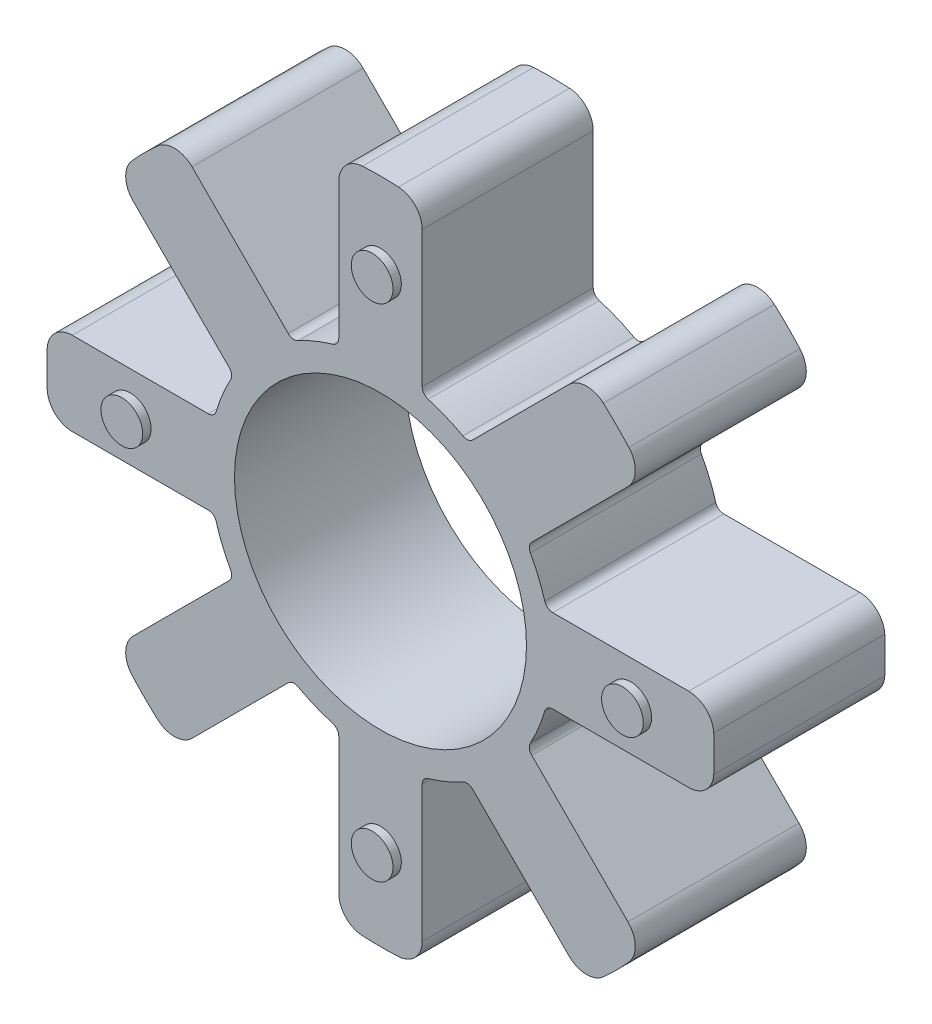
from build123d import *

# Parameters (mm, degrees)
SKETCH1_R           = 17.5
BOSS_EXTRUDE1_DEPTH = 10.25
SKETCH2_R           = 2.5
BOSS_EXTRUDE2_DEPTH = 1


with BuildPart() as part:
    # Sketch1 → Boss-Extrude1 (new body, symmetric)
    with BuildSketch(Plane.XY):
        with BuildLine():
            Line((-5, 36.945906404), (-5, 20.645822822))
            ThreePointArc((-5, 20.645822822), (-5.200290751, 20.04543535), (-5.720930233, 19.685551993))
            ThreePointArc((-5.720930233, 19.685551993), (-7.845010363, 18.939530416), (-9.874478744, 17.965095868))
            ThreePointArc((-9.874478744, 17.965095868), (-10.497102414, 17.851424122), (-11.063267415, 18.134335227))
            Line((-11.063267415, 18.134335227), (-22.589167049, 29.660234861))
            ThreePointArc((-22.589167049, 29.660234861), (-24.629376661, 30.537817825), (-26.714040425, 29.771799478))
            ThreePointArc((-26.714040425, 29.771799478), (-28.284271247, 28.284271247), (-29.771799478, 26.714040425))
            ThreePointArc((-29.771799478, 26.714040425), (-30.537817825, 24.629376661), (-29.660234861, 22.589167049))
            Line((-29.660234861, 22.589167049), (-18.134335227, 11.063267415))
            ThreePointArc((-18.134335227, 11.063267415), (-17.851424122, 10.497102414), (-17.965095868, 9.874478744))
            ThreePointArc((-17.965095868, 9.874478744), (-18.939530416, 7.845010363), (-19.685551993, 5.720930233))
            ThreePointArc((-19.685551993, 5.720930233), (-20.04543535, 5.200290751), (-20.645822822, 5))
            Line((-20.645822822, 5), (-36.945906404, 5))
            ThreePointArc((-36.945906404, 5), (-39.00909732, 4.177898814), (-39.941520437, 2.162162162))
            ThreePointArc((-39.941520437, 2.162162162), (-40, 0), (-39.941520437, -2.162162162))
            ThreePointArc((-39.941520437, -2.162162162), (-39.00909732, -4.177898814), (-36.945906404, -5))
            Line((-36.945906404, -5), (-20.645822822, -5))
            ThreePointArc((-20.645822822, -5), (-20.04543535, -5.200290751), (-19.685551993, -5.720930233))
            ThreePointArc((-19.685551993, -5.720930233), (-18.939530416, -7.845010363), (-17.965095868, -9.874478744))
            ThreePointArc((-17.965095868, -9.874478744), (-17.851424122, -10.497102414), (-18.134335227, -11.063267415))
            Line((-18.134335227, -11.063267415), (-29.660234861, -22.589167049))
            ThreePointArc((-29.660234861, -22.589167049), (-30.537817825, -24.629376661), (-29.771799478, -26.714040425))
            ThreePointArc((-29.771799478, -26.714040425), (-28.284271247, -28.284271247), (-26.714040425, -29.771799478))
            ThreePointArc((-26.714040425, -29.771799478), (-24.629376661, -30.537817825), (-22.589167049, -29.660234861))
            Line((-22.589167049, -29.660234861), (-11.063267415, -18.134335227))
            ThreePointArc((-11.063267415, -18.134335227), (-10.497102414, -17.851424122), (-9.874478744, -17.965095868))
            ThreePointArc((-9.874478744, -17.965095868), (-7.845010363, -18.939530416), (-5.720930233, -19.685551993))
            ThreePointArc((-5.720930233, -19.685551993), (-5.200290751, -20.04543535), (-5, -20.645822822))
            Line((-5, -20.645822822), (-5, -36.945906404))
            ThreePointArc((-5, -36.945906404), (-4.177898814, -39.00909732), (-2.162162162, -39.941520437))
            ThreePointArc((-2.162162162, -39.941520437), (0, -40), (2.162162162, -39.941520437))
            ThreePointArc((2.162162162, -39.941520437), (4.177898814, -39.00909732), (5, -36.945906404))
            Line((5, -36.945906404), (5, -20.645822822))
            ThreePointArc((5, -20.645822822), (5.200290751, -20.04543535), (5.720930233, -19.685551993))
            ThreePointArc((5.720930233, -19.685551993), (7.845010363, -18.939530416), (9.874478744, -17.965095868))
            ThreePointArc((9.874478744, -17.965095868), (10.497102414, -17.851424122), (11.063267415, -18.134335227))
            Line((11.063267415, -18.134335227), (22.589167049, -29.660234861))
            ThreePointArc((22.589167049, -29.660234861), (24.629376661, -30.537817825), (26.714040425, -29.771799478))
            ThreePointArc((26.714040425, -29.771799478), (28.284271247, -28.284271247), (29.771799478, -26.714040425))
            ThreePointArc((29.771799478, -26.714040425), (30.537817825, -24.629376661), (29.660234861, -22.589167049))
            Line((29.660234861, -22.589167049), (18.134335227, -11.063267415))
            ThreePointArc((18.134335227, -11.063267415), (17.851424122, -10.497102414), (17.965095868, -9.874478744))
            ThreePointArc((17.965095868, -9.874478744), (18.939530416, -7.845010363), (19.685551993, -5.720930233))
            ThreePointArc((19.685551993, -5.720930233), (20.04543535, -5.200290751), (20.645822822, -5))
            Line((20.645822822, -5), (36.945906404, -5))
            ThreePointArc((36.945906404, -5), (39.00909732, -4.177898814), (39.941520437, -2.162162162))
            ThreePointArc((39.941520437, -2.162162162), (40, 0), (39.941520437, 2.162162162))
            ThreePointArc((39.941520437, 2.162162162), (39.00909732, 4.177898814), (36.945906404, 5))
            Line((36.945906404, 5), (20.645822822, 5))
            ThreePointArc((20.645822822, 5), (20.04543535, 5.200290751), (19.685551993, 5.720930233))
            ThreePointArc((19.685551993, 5.720930233), (18.939530416, 7.845010363), (17.965095868, 9.874478744))
            ThreePointArc((17.965095868, 9.874478744), (17.851424122, 10.497102414), (18.134335227, 11.063267415))
            Line((18.134335227, 11.063267415), (29.660234861, 22.589167049))
            ThreePointArc((29.660234861, 22.589167049), (30.537817825, 24.629376661), (29.771799478, 26.714040425))
            ThreePointArc((29.771799478, 26.714040425), (28.284271247, 28.284271247), (26.714040425, 29.771799478))
            ThreePointArc((26.714040425, 29.771799478), (24.629376661, 30.537817825), (22.589167049, 29.660234861))
            Line((22.589167049, 29.660234861), (11.063267415, 18.134335227))
            ThreePointArc((11.063267415, 18.134335227), (10.497102414, 17.851424122), (9.874478744, 17.965095868))
            ThreePointArc((9.874478744, 17.965095868), (7.845010363, 18.939530416), (5.720930233, 19.685551993))
            ThreePointArc((5.720930233, 19.685551993), (5.200290751, 20.04543535), (5, 20.645822822))
            Line((5, 20.645822822), (5, 36.945906404))
            ThreePointArc((5, 36.945906404), (4.177898814, 39.00909732), (2.162162162, 39.941520437))
            ThreePointArc((2.162162162, 39.941520437), (0, 40), (-2.162162162, 39.941520437))
            ThreePointArc((-2.162162162, 39.941520437), (-4.177898814, 39.00909732), (-5, 36.945906404))
        make_face()
        Circle(SKETCH1_R, mode=Mode.SUBTRACT)
    extrude(amount=BOSS_EXTRUDE1_DEPTH, both=True)

    # Sketch2 → Boss-Extrude2 (add)
    with BuildSketch(Plane.XY.offset(10.25)):
        with Locations((0, 30)):
            Circle(SKETCH2_R)
        with Locations((30, 0)):
            Circle(SKETCH2_R)
        with Locations((0, -30)):
            Circle(SKETCH2_R)
        with Locations((-30, 0)):
            Circle(SKETCH2_R)
    boss_extrude2 = extrude(amount=BOSS_EXTRUDE2_DEPTH)

    # Mirror1: Boss-Extrude2 across plane
    add(boss_extrude2.mirror(Plane.XY))


solid = part.part
